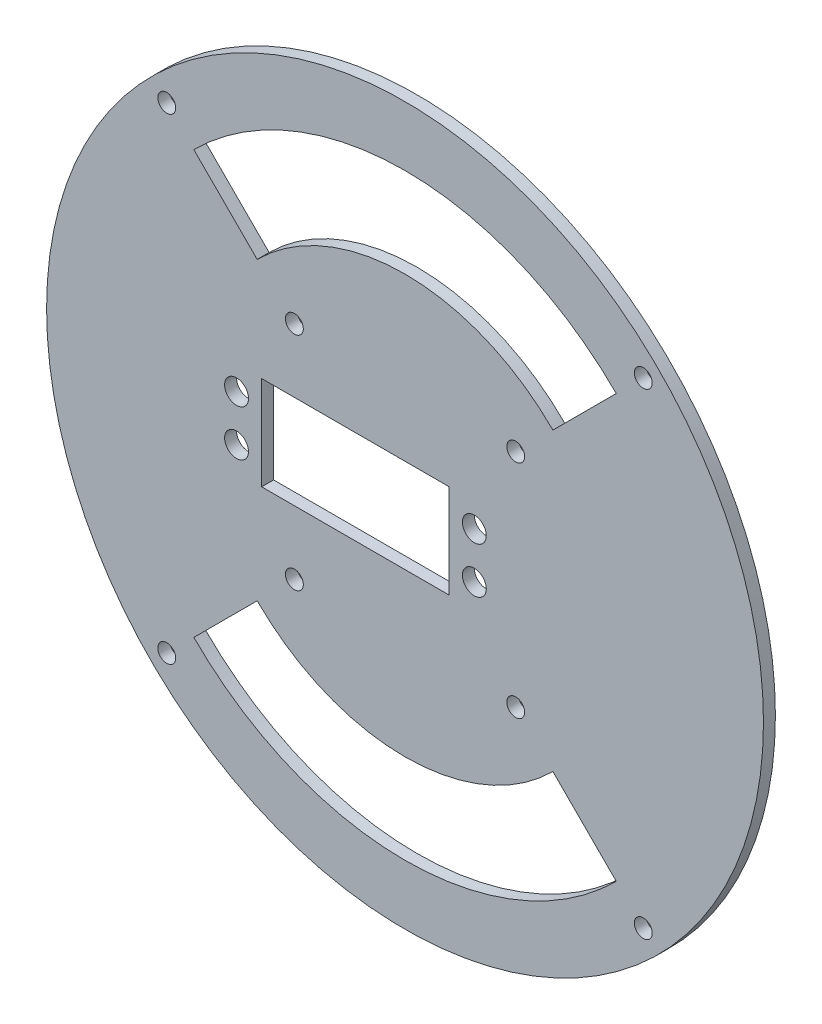
from build123d import *

# Parameters (mm, degrees)
SKETCH1_R           = 76.2
SKETCH1_R_2         = 2.54
SKETCH1_R_3         = 1.905
SKETCH1_W           = 39.878
SKETCH1_H           = 19.939
BOSS_EXTRUDE1_DEPTH = 2.54


with BuildPart() as part:
    # Sketch1 → Boss-Extrude1 (new body)
    with BuildSketch(Plane.XY):
        Circle(SKETCH1_R)
        with Locations((14.732, -4.8895)):
            Circle(SKETCH1_R_2, mode=Mode.SUBTRACT)
        with Locations((14.732, 4.8895)):
            Circle(SKETCH1_R_2, mode=Mode.SUBTRACT)
        with Locations((-35.814, 4.8895)):
            Circle(SKETCH1_R_2, mode=Mode.SUBTRACT)
        with Locations((-35.814, -4.8895)):
            Circle(SKETCH1_R_2, mode=Mode.SUBTRACT)
        with Locations((23.528271037, 23.528271037)):
            Circle(SKETCH1_R_3, mode=Mode.SUBTRACT)
        with Locations((23.528271037, -23.528271037)):
            Circle(SKETCH1_R_3, mode=Mode.SUBTRACT)
        with Locations((-23.528271037, -23.528271037)):
            Circle(SKETCH1_R_3, mode=Mode.SUBTRACT)
        with Locations((-23.528271037, 23.528271037)):
            Circle(SKETCH1_R_3, mode=Mode.SUBTRACT)
        with Locations((50.648644523, 50.648644523)):
            Circle(SKETCH1_R_3, mode=Mode.SUBTRACT)
        with Locations((50.648644523, -50.648644523)):
            Circle(SKETCH1_R_3, mode=Mode.SUBTRACT)
        with Locations((-50.648644523, -50.648644523)):
            Circle(SKETCH1_R_3, mode=Mode.SUBTRACT)
        with Locations((-50.648644523, 50.648644523)):
            Circle(SKETCH1_R_3, mode=Mode.SUBTRACT)
        with Locations((-10.541, 0)):
            Rectangle(SKETCH1_W, SKETCH1_H, mode=Mode.SUBTRACT)
        with BuildLine():
            Line((-44.901280605, -44.901280605), (-31.430896424, -31.430896424))
            ThreePointArc((-31.430896424, -31.430896424), (0, -44.45), (31.430896424, -31.430896424))
            Line((31.430896424, -31.430896424), (44.901280605, -44.901280605))
            ThreePointArc((44.901280605, -44.901280605), (0, -63.5), (-44.901280605, -44.901280605))
        make_face(mode=Mode.SUBTRACT)
        with BuildLine():
            Line((44.901280605, 44.901280605), (31.430896424, 31.430896424))
            ThreePointArc((31.430896424, 31.430896424), (0, 44.45), (-31.430896424, 31.430896424))
            Line((-31.430896424, 31.430896424), (-44.901280605, 44.901280605))
            ThreePointArc((-44.901280605, 44.901280605), (0, 63.5), (44.901280605, 44.901280605))
        make_face(mode=Mode.SUBTRACT)
    extrude(amount=BOSS_EXTRUDE1_DEPTH)


solid = part.part
